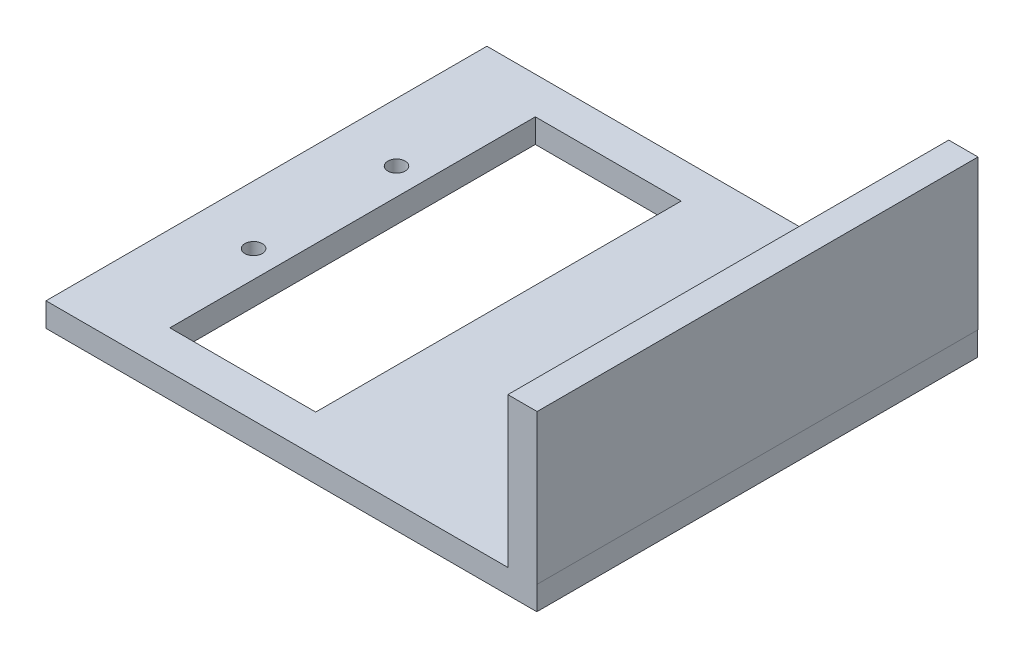
from build123d import *

# Parameters (mm, degrees)
SKETCH1_W           = 82
SKETCH1_H           = 73.66
BOSS_EXTRUDE1_DEPTH = 4
SKETCH2_W           = 4.88717895
SKETCH2_H           = 73.66
BOSS_EXTRUDE2_DEPTH = 25
SKETCH3_R           = 1.45
CUT_EXTRUDE1_DEPTH  = 10
SKETCH4_W           = 24.37
SKETCH4_H           = 61.062715067
CUT_EXTRUDE2_DEPTH  = 10


with BuildPart() as part:
    # Sketch1 → Boss-Extrude1 (new body)
    with BuildSketch(Plane(origin=(0, 0, 0), x_dir=(1, 0, 0), z_dir=(0, 1, 0))):
        with Locations((0.667646454, -2.157941762)):
            Rectangle(SKETCH1_W, SKETCH1_H)
    extrude(amount=BOSS_EXTRUDE1_DEPTH)

    # Sketch2 → Boss-Extrude2 (add)
    with BuildSketch(Plane(origin=(0, 4, 0), x_dir=(1, 0, 0), z_dir=(0, 1, 0))):
        with Locations((39.271911138, -2.157941762)):
            Rectangle(SKETCH2_W, SKETCH2_H)
    extrude(amount=BOSS_EXTRUDE2_DEPTH)

    # Sketch3 → Cut-Extrude1 (cut)
    with BuildSketch(Plane(origin=(0, 4, 0), x_dir=(1, 0, 0), z_dir=(0, 1, 0))):
        with Locations((-30.544050148, 9.782058238)):
            Circle(SKETCH3_R)
        with Locations((-30.544050148, -14.097941762)):
            Circle(SKETCH3_R)
    extrude(amount=-CUT_EXTRUDE1_DEPTH, mode=Mode.SUBTRACT)

    # Sketch4 → Cut-Extrude2 (cut)
    with BuildSketch(Plane(origin=(0, 4, 0), x_dir=(1, 0, 0), z_dir=(0, 1, 0))):
        with Locations((-13.885112628, -2.028636366)):
            Rectangle(SKETCH4_W, SKETCH4_H)
    extrude(amount=-CUT_EXTRUDE2_DEPTH, mode=Mode.SUBTRACT)


solid = part.part
